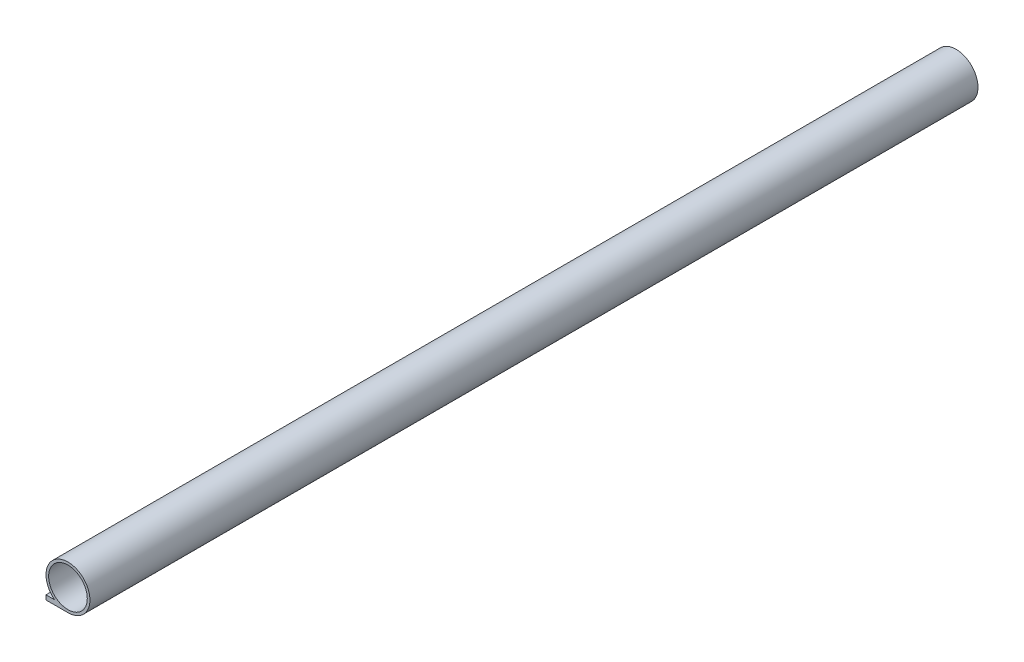
from build123d import *

# Parameters (mm, degrees)
SKETCH1_R           = 11.176
BOSS_EXTRUDE1_DEPTH = 513.588
SKETCH2_W           = 511.048
SKETCH2_H           = 1.5875
CUT_EXTRUDE1_DEPTH  = 5.08


with BuildPart() as part:
    # Sketch1 → Boss-Extrude1 (new body)
    with BuildSketch(Plane.XY):
        with BuildLine():
            Line((0, -12.7), (-12.7, -12.7))
            Line((-12.7, -12.7), (-12.7, -10.0965))
            Line((-12.7, -10.0965), (-7.703939755, -10.0965))
            ThreePointArc((-7.703939755, -10.0965), (4.065983891, 12.031532529), (0, -12.7))
        make_face()
        Circle(SKETCH1_R, mode=Mode.SUBTRACT)
    extrude(amount=BOSS_EXTRUDE1_DEPTH)

    # Sketch2 → Cut-Extrude1 (cut)
    with BuildSketch(Plane.ZY.offset(12.7)):
        with Locations((256.794, -11.39825)):
            Rectangle(SKETCH2_W, SKETCH2_H)
    extrude(amount=-CUT_EXTRUDE1_DEPTH, mode=Mode.SUBTRACT)


solid = part.part
